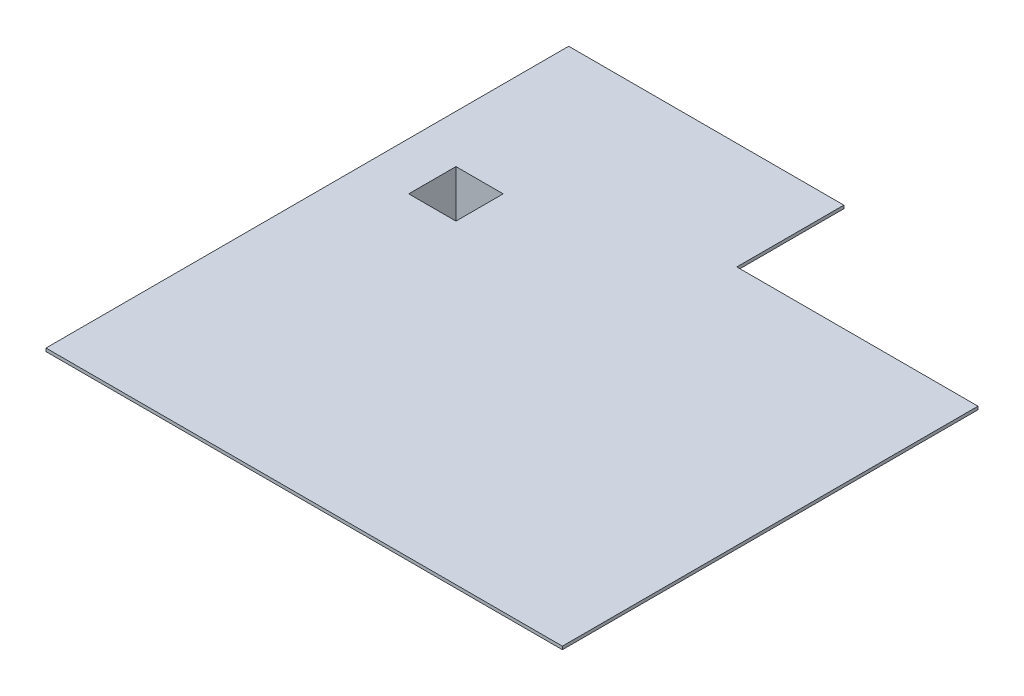
from build123d import *

# Parameters (mm, degrees)
EXTRUDE_1_DEPTH     = 100
SKETCH_5_W          = 1700
SKETCH_5_H          = 1700
SKETCH_5_W_2        = 1500
SKETCH_5_H_2        = 1500
EXTRUDE_3_DEPTH     = 2200
SKETCH_5_3_W        = 1500
SKETCH_5_3_H        = 1500
CUT_EXTRUDE_3_DEPTH = 2200


with BuildPart() as part:
    # Эскиз1 → Вытянуть1 (new body)
    with BuildSketch(Plane(origin=(0, 0, 0), x_dir=(1, 0, 0), z_dir=(0, 1, 0))):
        Polygon((16400, 13200), (8740, 13200), (8740, 16600), (0, 16600), (0, 0), (16400, 0), align=None)
    extrude(amount=EXTRUDE_1_DEPTH)

    # Эскиз5 → Вытянуть-Тонкостенный3 (add)
    with BuildSketch(Plane(origin=(0, 100, 0), x_dir=(1, 0, 0), z_dir=(0, 1, 0))):
        with Locations((2270, 10750)):
            Rectangle(SKETCH_5_W, SKETCH_5_H)
        with Locations((2270, 10750)):
            Rectangle(SKETCH_5_W_2, SKETCH_5_H_2, mode=Mode.SUBTRACT)
    extrude(amount=-EXTRUDE_3_DEPTH)

    # Эскиз5<3> → Вытянуть3 (cut)
    with BuildSketch(Plane(origin=(0, 100, 0), x_dir=(1, 0, 0), z_dir=(0, 1, 0))):
        with Locations((2270, 10750)):
            Rectangle(SKETCH_5_3_W, SKETCH_5_3_H)
    extrude(amount=-CUT_EXTRUDE_3_DEPTH, mode=Mode.SUBTRACT)


solid = part.part
